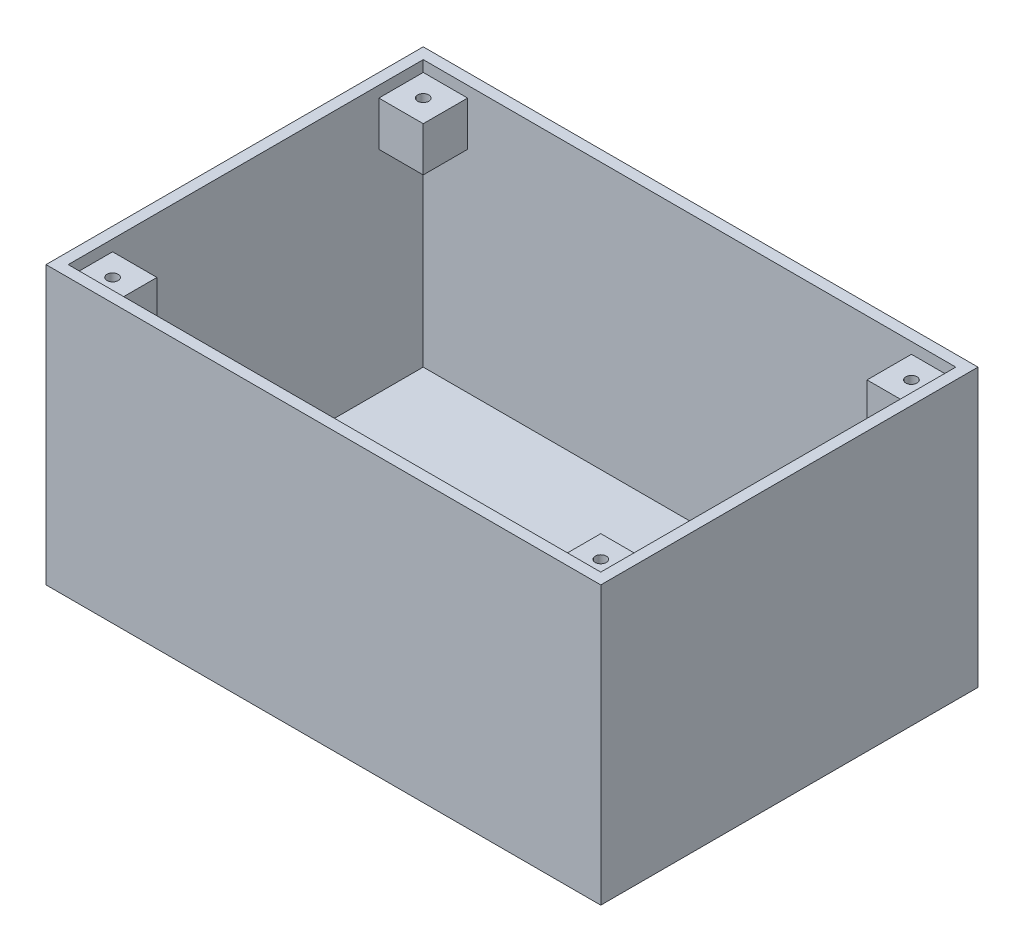
from build123d import *

# Parameters (mm, degrees)
SKETCH1_W             = 317.5
SKETCH1_H             = 215.9
BOSS_EXTRUDE1_DEPTH   = 6.35
SKETCH2_W             = 317.5
SKETCH2_H             = 215.9
SKETCH2_W_2           = 304.8
SKETCH2_H_2           = 203.2
BOSS_EXTRUDE2_DEPTH   = 152.4
SKETCH3_W             = 25.4
SKETCH3_H             = 25.4
BOSS_EXTRUDE3_DEPTH   = 25.4
BOSS_EXTRUDE3_2_DEPTH = 25.4
SKETCH5_W             = 25.4
SKETCH5_H             = 25.4
BOSS_EXTRUDE5_DEPTH   = 25.4
BOSS_EXTRUDE5_2_DEPTH = 25.4
SKETCH6_R             = 3.175
CUT_EXTRUDE1_DEPTH    = 15.24


with BuildPart() as part:
    # Sketch1 → Boss-Extrude1 (new body)
    with BuildSketch(Plane(origin=(0, 0, 0), x_dir=(1, 0, 0), z_dir=(0, 1, 0))):
        Rectangle(SKETCH1_W, SKETCH1_H)
    extrude(amount=BOSS_EXTRUDE1_DEPTH)

    # Sketch2 → Boss-Extrude2 (add)
    with BuildSketch(Plane(origin=(0, 6.35, 0), x_dir=(1, 0, 0), z_dir=(0, 1, 0))):
        Rectangle(SKETCH2_W, SKETCH2_H)
        Rectangle(SKETCH2_W_2, SKETCH2_H_2, mode=Mode.SUBTRACT)
    extrude(amount=BOSS_EXTRUDE2_DEPTH)


with BuildPart() as body_2:
    # Sketch3 → Boss-Extrude3 (new body)
    with BuildSketch(Plane.XY.offset(-101.6)):
        with Locations((-139.7, 139.7)):
            Rectangle(SKETCH3_W, SKETCH3_H)
    extrude(amount=BOSS_EXTRUDE3_DEPTH)


with BuildPart() as body_3:
    # Sketch3 → Boss-Extrude3 2 (new body)
    with BuildSketch(Plane.XY.offset(-101.6)):
        with Locations((139.7, 139.7)):
            Rectangle(SKETCH3_W, SKETCH3_H)
    extrude(amount=BOSS_EXTRUDE3_2_DEPTH)


with BuildPart() as body_4:
    # Sketch5 → Boss-Extrude5 (new body)
    with BuildSketch(Plane(origin=(0, 0, 101.6), x_dir=(-1, 0, 0), z_dir=(0, 0, -1))):
        with Locations((-139.7, 139.7)):
            Rectangle(SKETCH5_W, SKETCH5_H)
    extrude(amount=BOSS_EXTRUDE5_DEPTH)


with BuildPart() as body_5:
    # Sketch5 → Boss-Extrude5 2 (new body)
    with BuildSketch(Plane(origin=(0, 0, 101.6), x_dir=(-1, 0, 0), z_dir=(0, 0, -1))):
        with Locations((139.7, 139.7)):
            Rectangle(SKETCH5_W, SKETCH5_H)
    extrude(amount=BOSS_EXTRUDE5_2_DEPTH)


with BuildPart() as cut_extrude1_tool:
    # Sketch6 → Cut-Extrude1 (new body)
    with BuildSketch(Plane(origin=(0, 152.4, 0), x_dir=(1, 0, 0), z_dir=(0, 1, 0))):
        with Locations((139.7, -88.9)):
            Circle(SKETCH6_R)
        with Locations((-139.7, -88.9)):
            Circle(SKETCH6_R)
        with Locations((-139.7, 88.9)):
            Circle(SKETCH6_R)
        with Locations((139.7, 88.9)):
            Circle(SKETCH6_R)
    extrude(amount=-CUT_EXTRUDE1_DEPTH)


with BuildPart() as body_2_1:
    add(body_2.part)

    # Cut-Extrude1: cut by cut_extrude1_tool
    add(cut_extrude1_tool.part, mode=Mode.SUBTRACT)


with BuildPart() as body_3_1:
    add(body_3.part)

    # Cut-Extrude1: cut by cut_extrude1_tool
    add(cut_extrude1_tool.part, mode=Mode.SUBTRACT)


with BuildPart() as body_4_1:
    add(body_4.part)

    # Cut-Extrude1: cut by cut_extrude1_tool
    add(cut_extrude1_tool.part, mode=Mode.SUBTRACT)


with BuildPart() as body_5_1:
    add(body_5.part)

    # Cut-Extrude1: cut by cut_extrude1_tool
    add(cut_extrude1_tool.part, mode=Mode.SUBTRACT)


solid = Compound([part.part, body_2_1.part, body_3_1.part, body_4_1.part, body_5_1.part])
